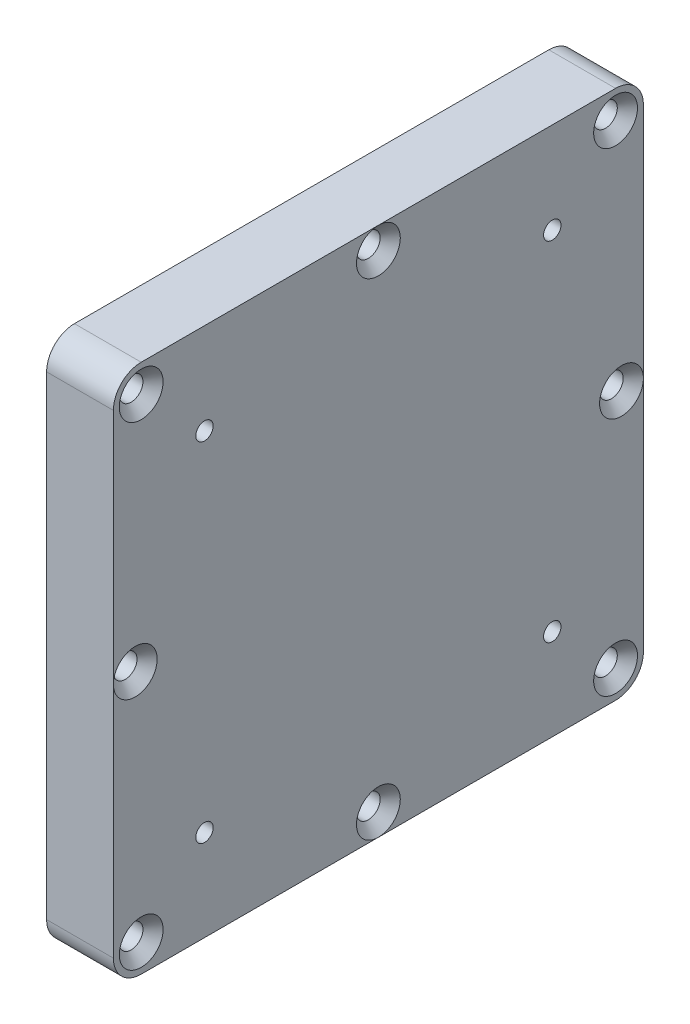
from build123d import *

# Parameters (mm, degrees)
BOSS_EXTRUDE1_DEPTH                             = 9.6
CSK_FOR_M3_FLAT_HEAD_MACHINE_SCREW1_D           = 3.4
CSK_FOR_M3_FLAT_HEAD_MACHINE_SCREW1_CSINK_D     = 6.3
CSK_FOR_M3_FLAT_HEAD_MACHINE_SCREW1_CSINK_ANGLE = 90
M3X0_5_TAPPED_HOLE1_D                           = 2.5
M3X0_5_TAPPED_HOLE1_DEPTH                       = 6.748924226
M3X0_5_TAPPED_HOLE1_TIP                         = 0.751075774


with BuildPart() as part:
    # Sketch2 → Boss-Extrude1 (new body)
    with BuildSketch(Plane(origin=(0, 0, 0), x_dir=(0, 0, -1), z_dir=(1, 0, 0))):
        with BuildLine():
            Line((-34.1, -38.1), (34.1, -38.1))
            ThreePointArc((34.1, -38.1), (36.928427125, -36.928427125), (38.1, -34.1))
            Line((38.1, -34.1), (38.1, 34.1))
            ThreePointArc((38.1, 34.1), (36.928427125, 36.928427125), (34.1, 38.1))
            Line((34.1, 38.1), (-34.1, 38.1))
            ThreePointArc((-34.1, 38.1), (-36.928427125, 36.928427125), (-38.1, 34.1))
            Line((-38.1, 34.1), (-38.1, -34.1))
            ThreePointArc((-38.1, -34.1), (-36.928427125, -36.928427125), (-34.1, -38.1))
        make_face()
    extrude(amount=BOSS_EXTRUDE1_DEPTH)

    # CSK for M3 Flat Head Machine Screw1 (through all)
    with Locations(Plane(origin=(9.6, 0, 0), x_dir=(0, 0, 1), z_dir=(1, 0, 0))):
        with Locations((-34.100008, -34.1), (34.1, -34.1), (34.1, 34.1), (-34.100008, 34.1), (0, -34.94999995), (34.95, 0), (0, 34.95), (-34.95, 0)):
            CounterSinkHole(CSK_FOR_M3_FLAT_HEAD_MACHINE_SCREW1_D / 2, CSK_FOR_M3_FLAT_HEAD_MACHINE_SCREW1_CSINK_D / 2, counter_sink_angle=CSK_FOR_M3_FLAT_HEAD_MACHINE_SCREW1_CSINK_ANGLE)

    # M3x0.5 Tapped Hole1
    with Locations(Plane(origin=(9.6, 0, 0), x_dir=(0, 0, -1), z_dir=(1, 0, 0))):
        with Locations((-25, 25), (25, 25), (25, -25), (-25, -25)):
            Hole(M3X0_5_TAPPED_HOLE1_D / 2, depth=M3X0_5_TAPPED_HOLE1_DEPTH)
            with Locations((0, 0, -(M3X0_5_TAPPED_HOLE1_DEPTH + M3X0_5_TAPPED_HOLE1_TIP / 2))):  # 118° drill point
                Cone(0, M3X0_5_TAPPED_HOLE1_D / 2, M3X0_5_TAPPED_HOLE1_TIP, mode=Mode.SUBTRACT)


solid = part.part
